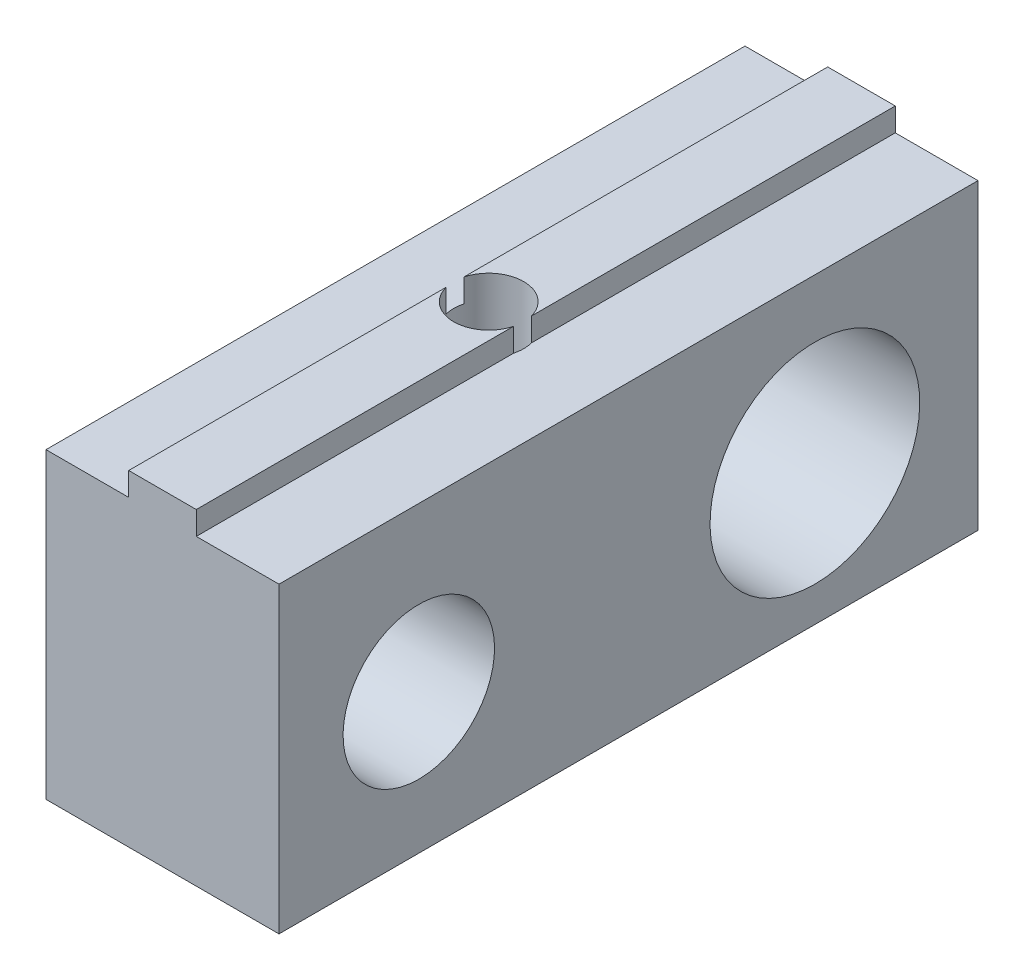
from build123d import *

# Parameters (mm, degrees)
MAKERBEAMFIX_DEPTH              = 15
SKETCH3_W                       = 30
SKETCH3_H                       = 12
SKETCH3_R                       = 3.25
SKETCH3_R_2                     = 4.5
DRILLKEYANDSMALLHEXDRIVER_DEPTH = 10
SKETCH4_R                       = 1.5
FIXINGHOLE_DEPTH                = 15
SKETCH5_R                       = 4.25
DRIVERHOLE_DEPTH                = 7


with BuildPart() as part:
    # Sketch1 → MakerBeamFix (new body, symmetric)
    with BuildSketch(Plane.XY):
        Polygon((-5, 0), (5, 0), (5, 1), (1.45, 1), (1.45, 2), (-1.45, 2), (-1.45, 1), (-5, 1), align=None)
    extrude(amount=MAKERBEAMFIX_DEPTH, both=True)

    # Sketch3 → DrillKeyAndSmallHexDriver (add)
    with BuildSketch(Plane.ZY.offset(5)):
        with Locations((0, -6)):
            Rectangle(SKETCH3_W, SKETCH3_H)
        with Locations((9, -6)):
            Circle(SKETCH3_R, mode=Mode.SUBTRACT)
        with Locations((-8, -6)):
            Circle(SKETCH3_R_2, mode=Mode.SUBTRACT)
    extrude(amount=-DRILLKEYANDSMALLHEXDRIVER_DEPTH)

    # Sketch4 → FixingHole (cut, through all)
    with BuildSketch(Plane.XZ.offset(12)):
        with Locations((0, 1)):
            Circle(SKETCH4_R)
    extrude(amount=-FIXINGHOLE_DEPTH, mode=Mode.SUBTRACT)

    # Sketch5 → DriverHole (cut, through all)
    with BuildSketch(Plane(origin=(0, -6, 0), x_dir=(1, 0, 0), z_dir=(0, 1, 0))):
        with Locations((0, -1)):
            Circle(SKETCH5_R)
    extrude(amount=-DRIVERHOLE_DEPTH, mode=Mode.SUBTRACT)


solid = part.part
